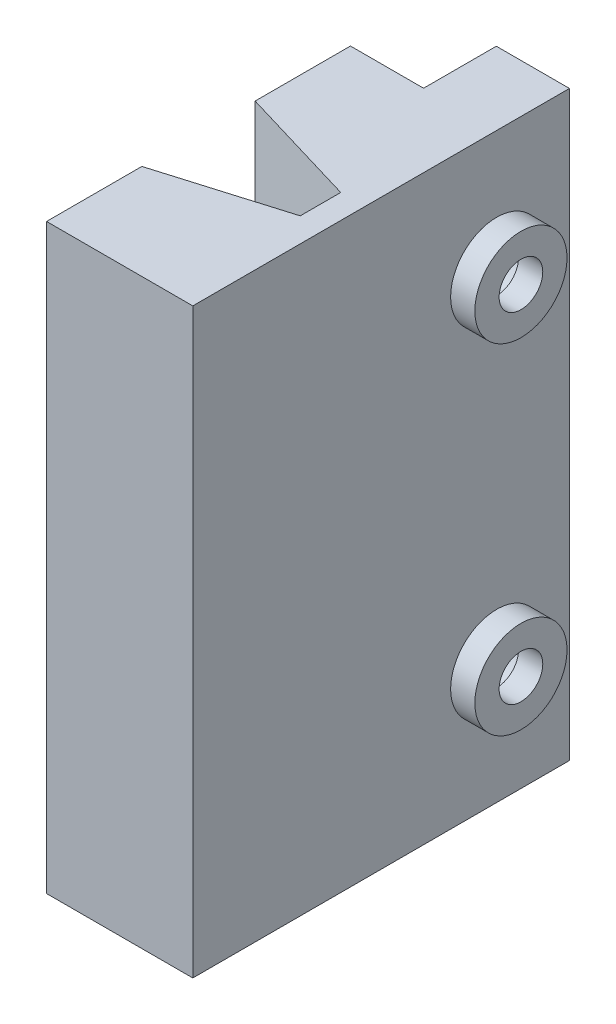
from build123d import *

# Parameters (mm, degrees)
BOSS_EXTRUDE1_DEPTH = 24
SKETCH7_W           = 3.015
SKETCH7_H           = 24
BOSS_EXTRUDE3_DEPTH = 3
SKETCH3_R           = 1.9
SKETCH3_R_2         = 0.9
BOSS_EXTRUDE2_DEPTH = 1
SKETCH4_R           = 1.15
CUT_EXTRUDE2_DEPTH  = 23
CUT_EXTRUDE3_DEPTH  = 30


with BuildPart() as part:
    # Sketch1 → Boss-Extrude1 (new body)
    with BuildSketch(Plane(origin=(0, 0, 0), x_dir=(1, 0, 0), z_dir=(0, 1, 0))):
        Polygon((0.758759529, 5.315), (5, 5.315), (5, -7.215), (1.398203198, -7.215), (-1.03, -7.215), (-1.03, -1.785), (4, -1.785), (4, -0.115), (-1.03, -0.115), (-1.03, 5.315), align=None)
    extrude(amount=BOSS_EXTRUDE1_DEPTH)

    # Sketch7 → Boss-Extrude3 (add)
    with BuildSketch(Plane(origin=(0, 0, -5.315), x_dir=(-1, 0, 0), z_dir=(0, 0, -1))):
        with Locations((-3.4925, 12)):
            Rectangle(SKETCH7_W, SKETCH7_H)
    extrude(amount=BOSS_EXTRUDE3_DEPTH)

    # Sketch3 → Boss-Extrude2 (add)
    with BuildSketch(Plane(origin=(5, 0, 0), x_dir=(0, 0, -1), z_dir=(1, 0, 0))):
        with Locations((5.315, 19)):
            Circle(SKETCH3_R)
        with Locations((5.315, 19)):
            Circle(SKETCH3_R_2, mode=Mode.SUBTRACT)
        with Locations((5.315, 5)):
            Circle(SKETCH3_R)
        with Locations((5.315, 5)):
            Circle(SKETCH3_R_2, mode=Mode.SUBTRACT)
    extrude(amount=BOSS_EXTRUDE2_DEPTH)

    # Sketch4 → Cut-Extrude2 (cut)
    with BuildSketch(Plane(origin=(5, 0, 0), x_dir=(0, 0, -1), z_dir=(1, 0, 0))):
        with Locations((5.315, 19)):
            Circle(SKETCH4_R)
        with Locations((5.315, 5)):
            Circle(SKETCH4_R)
    extrude(amount=-CUT_EXTRUDE2_DEPTH, mode=Mode.SUBTRACT)

    # Sketch6 → Cut-Extrude3 (cut)
    with BuildSketch(Plane(origin=(0, 24, 0), x_dir=(1, 0, 0), z_dir=(0, 1, 0))):
        Polygon((-1.03, -0.115), (4, -0.115), (-1.03, 1.385), align=None)
        Polygon((4, -1.785), (-1.03, -1.785), (-1.03, -3.285), align=None)
    extrude(amount=-CUT_EXTRUDE3_DEPTH, mode=Mode.SUBTRACT)


solid = part.part
